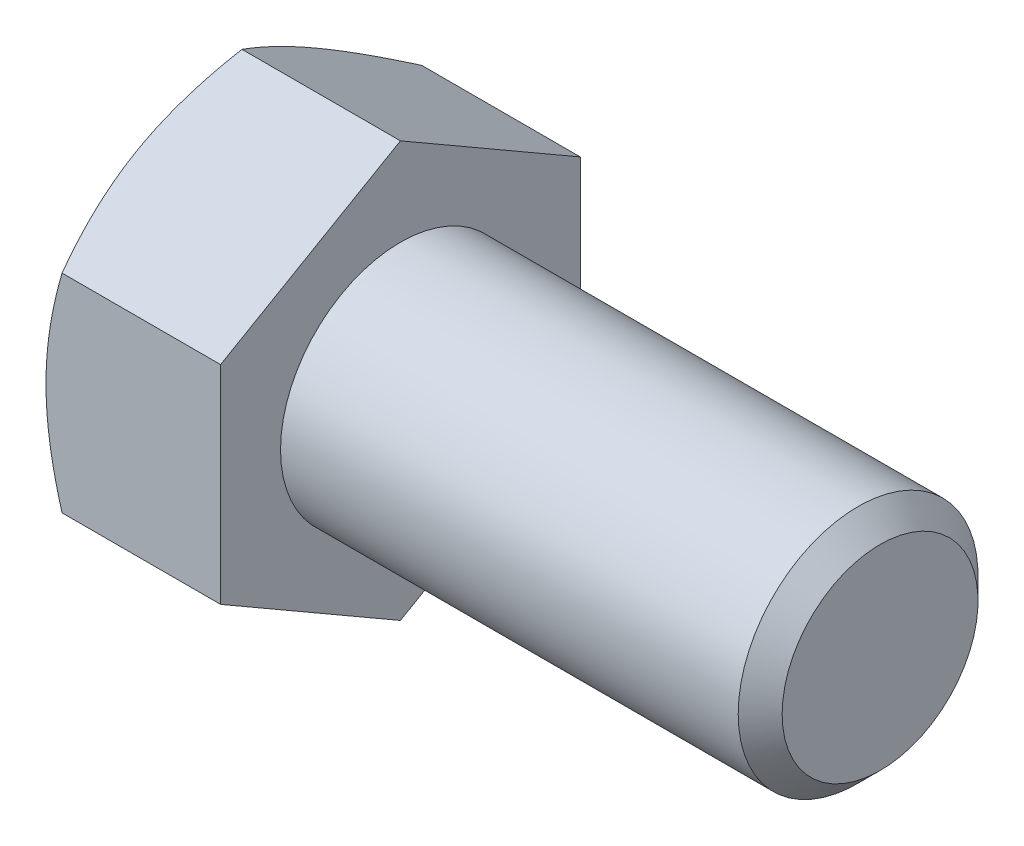
from build123d import *

# Parameters (mm, degrees)
BASEHEAD_DEPTH = 9.2456


with BuildPart() as part:
    # Sketch1 → BaseHead (new body)
    with BuildSketch(Plane(origin=(0, 0, 0), x_dir=(0, 0, -1), z_dir=(1, 0, 0))):
        Polygon((9.525, 5.499261314), (9.525, -5.499261314), (0, -10.998522628), (-9.525, -5.499261314), (-9.525, 5.499261314), (0, 10.998522628), align=None)
    extrude(amount=BASEHEAD_DEPTH)

    # BodySke → BaseBody (revolve)
    with BuildSketch(Plane.XY):
        Polygon((0, 0), (34.6456, 0), (34.6456, 5.18668), (33.48228, 6.35), (0, 6.35), align=None)
    revolve(axis=Axis((0, 0, 0), (1, 0, 0)))

    # Sketch3 → HeadChamfer (revolve, cut)
    with BuildSketch(Plane.XY):
        Polygon((0, 9.525), (4.516912895, 17.348522628), (4.516912895, 23.698522628), (-12.7, 23.698522628), (-12.7, 9.525), align=None)
    revolve(axis=Axis((0, 0, 0), (1, 0, 0)), mode=Mode.SUBTRACT)


solid = part.part
